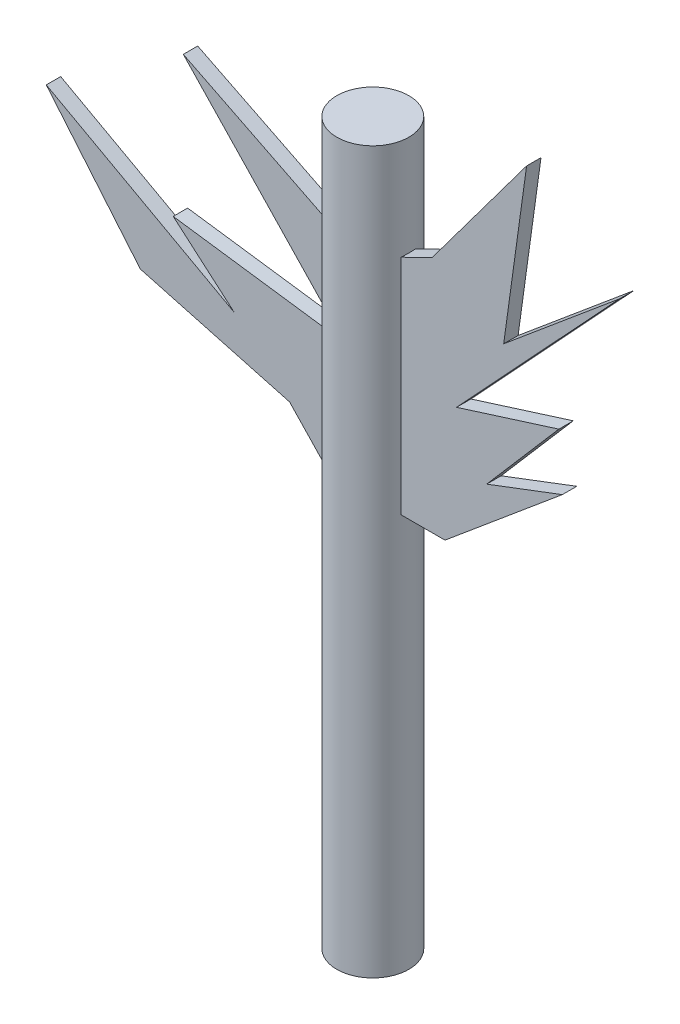
from build123d import *

# Parameters (mm, degrees)
SKETCH_1_R           = 25
EXTRUDE_1_DEPTH      = 500
EXTRUDE_2_DEPTH      = 5
EXTRUDE_2_DEPTH_BACK = 5


with BuildPart() as part:
    # 草图1 → 凸台-拉伸1 (new body)
    with BuildSketch(Plane(origin=(0, 0, 0), x_dir=(1, 0, 0), z_dir=(0, 1, 0))):
        Circle(SKETCH_1_R)
    extrude(amount=EXTRUDE_1_DEPTH)

    # 草图2 → 凸台-拉伸2 (add, two sides: drawn at the far end of the back side and taken through both)
    with BuildSketch(Plane.XY.offset(-EXTRUDE_2_DEPTH_BACK)):
        Polygon((-4.904147501, 415.869728805), (-126.476794097, 476.563858447), (-14.845338431, 359.271534235), (-133.474875453, 375.696686665), (-91.053404274, 339.123990271), (-221.536557101, 410.673201002), (-156.294980688, 332.640319032), (-52.729774464, 304.574199064), (-25, 275.438238439), (55.079469547, 275.438238439), (136.510624595, 343.521036234), (84.009054298, 323.576399455), (134.080402497, 381.655252369), (63.084510335, 359.271534235), (176.005774191, 480.837199539), (95.795047071, 413.774774694), (111.692244322, 528.591191642), (46.07245174, 440.657183354), align=None)
    extrude(amount=EXTRUDE_2_DEPTH + EXTRUDE_2_DEPTH_BACK)


solid = part.part
